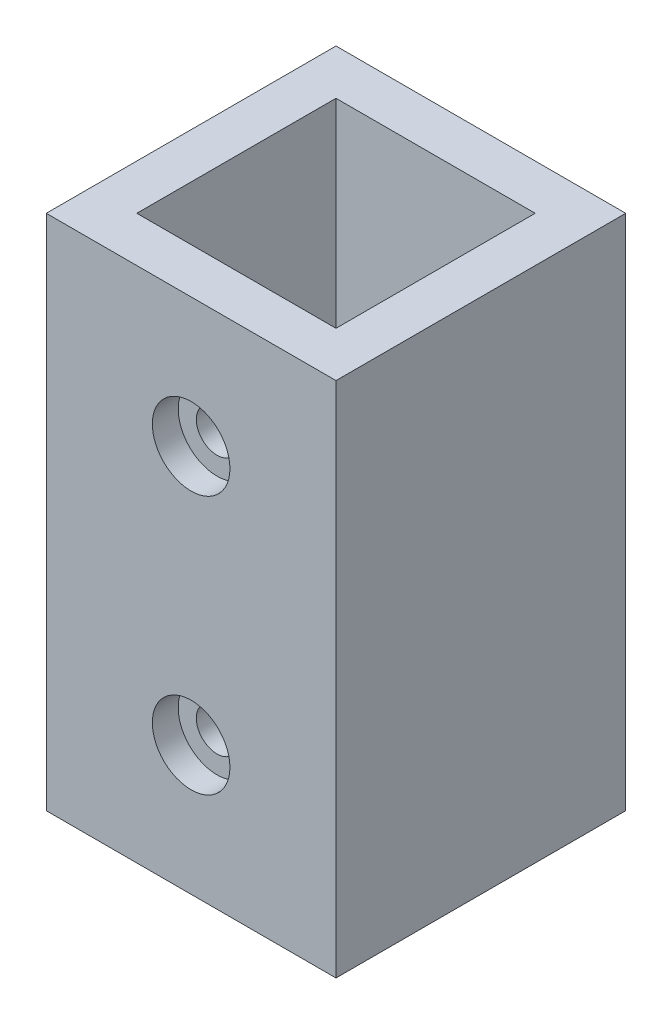
from build123d import *

# Parameters (mm, degrees)
SKETCH_1_W          = 15.4
SKETCH_1_H          = 22.4
EXTRUDE_2_DEPTH     = 3
SKETCH_1_4_W        = 15.4
SKETCH_1_4_H        = 3.5
EXTRUDE_3_DEPTH     = 10
EXTRUDE_3_2_DEPTH   = 10
SKETCH_1_5_W        = 22.4
SKETCH_1_5_H        = 22.4
SKETCH_1_5_W_2      = 15.4
SKETCH_1_5_H_2      = 15.4
EXTRUDE_4_DEPTH     = 40
SKETCH_3_R          = 1.6
CUT_EXTRUDE_2_DEPTH = 52.711507423
SKETCH_10_R         = 3
CUT_EXTRUDE_7_DEPTH = 2
CUT_EXTRUDE_START   = -2
SKETCH_11_R         = 3
CUT_EXTRUDE_8_DEPTH = 2
SKETCH_12_W         = 15.4
SKETCH_12_H         = 15.4
CUT_EXTRUDE_9_DEPTH = 41.247732855


with BuildPart() as part:
    # 草图1 → 凸台-拉伸2 (new body)
    with BuildSketch(Plane(origin=(0, 0, 0), x_dir=(1, 0, 0), z_dir=(0, 1, 0))):
        Rectangle(SKETCH_1_W, SKETCH_1_H)
    extrude(amount=EXTRUDE_2_DEPTH)



with BuildPart() as body_2:
    # 草图1<4> → 凸台-拉伸3 (new body)
    with BuildSketch(Plane(origin=(0, 0, 0), x_dir=(1, 0, 0), z_dir=(0, 1, 0))):
        with Locations((0, 9.45)):
            Rectangle(SKETCH_1_4_W, SKETCH_1_4_H)
    extrude(amount=EXTRUDE_3_DEPTH)


with BuildPart() as body_3:
    # 草图1<4> → Extrude 3 2 (new body)
    with BuildSketch(Plane(origin=(0, 0, 0), x_dir=(1, 0, 0), z_dir=(0, 1, 0))):
        with Locations((0, -9.45)):
            Rectangle(SKETCH_1_4_W, SKETCH_1_4_H)
    extrude(amount=EXTRUDE_3_2_DEPTH)


with BuildPart() as part_1:
    add(part.part)

    add(body_2.part)  # 凸台-拉伸4 merges body 2

    add(body_3.part)  # 凸台-拉伸4 merges body 3
    # 草图1<5> → 凸台-拉伸4 (add)
    with BuildSketch(Plane(origin=(0, 0, 0), x_dir=(1, 0, 0), z_dir=(0, 1, 0))):
        Rectangle(SKETCH_1_5_W, SKETCH_1_5_H)
        Rectangle(SKETCH_1_5_W_2, SKETCH_1_5_H_2, mode=Mode.SUBTRACT)
    extrude(amount=EXTRUDE_4_DEPTH)

    # 草图3 → 切除-拉伸2 (cut, through all)
    with BuildSketch(Plane(origin=(0, 0, -19.6), x_dir=(-1, 0, 0), z_dir=(0, 0, -1))):
        with Locations((0, 10)):
            Circle(SKETCH_3_R)
        with Locations((0, 30)):
            Circle(SKETCH_3_R)
    extrude(amount=-CUT_EXTRUDE_2_DEPTH, mode=Mode.SUBTRACT)

    # 草图10 → 切除-拉伸7 (cut)
    with BuildSketch(Plane(origin=(0, 0, -11.2), x_dir=(-1, 0, 0), z_dir=(0, 0, -1))):
        with Locations((0, 30)):
            Circle(SKETCH_10_R)
        with Locations((0, 10)):
            Circle(SKETCH_10_R)
    extrude(amount=-CUT_EXTRUDE_7_DEPTH, mode=Mode.SUBTRACT)

    # 草图11 → 切除-拉伸8 (cut)
    with BuildSketch(Plane.XY.offset(11.2).offset(CUT_EXTRUDE_START)):
        with Locations((0, 30)):
            Circle(SKETCH_11_R)
        with Locations((0, 10)):
            Circle(SKETCH_11_R)
    extrude(amount=CUT_EXTRUDE_8_DEPTH, mode=Mode.SUBTRACT)

    # 草图12 → 切除-拉伸9 (cut, through all)
    with BuildSketch(Plane(origin=(0, 3, 0), x_dir=(1, 0, 0), z_dir=(0, 1, 0))):
        Rectangle(SKETCH_12_W, SKETCH_12_H)
    extrude(amount=-CUT_EXTRUDE_9_DEPTH, mode=Mode.SUBTRACT)


solid = part_1.part
